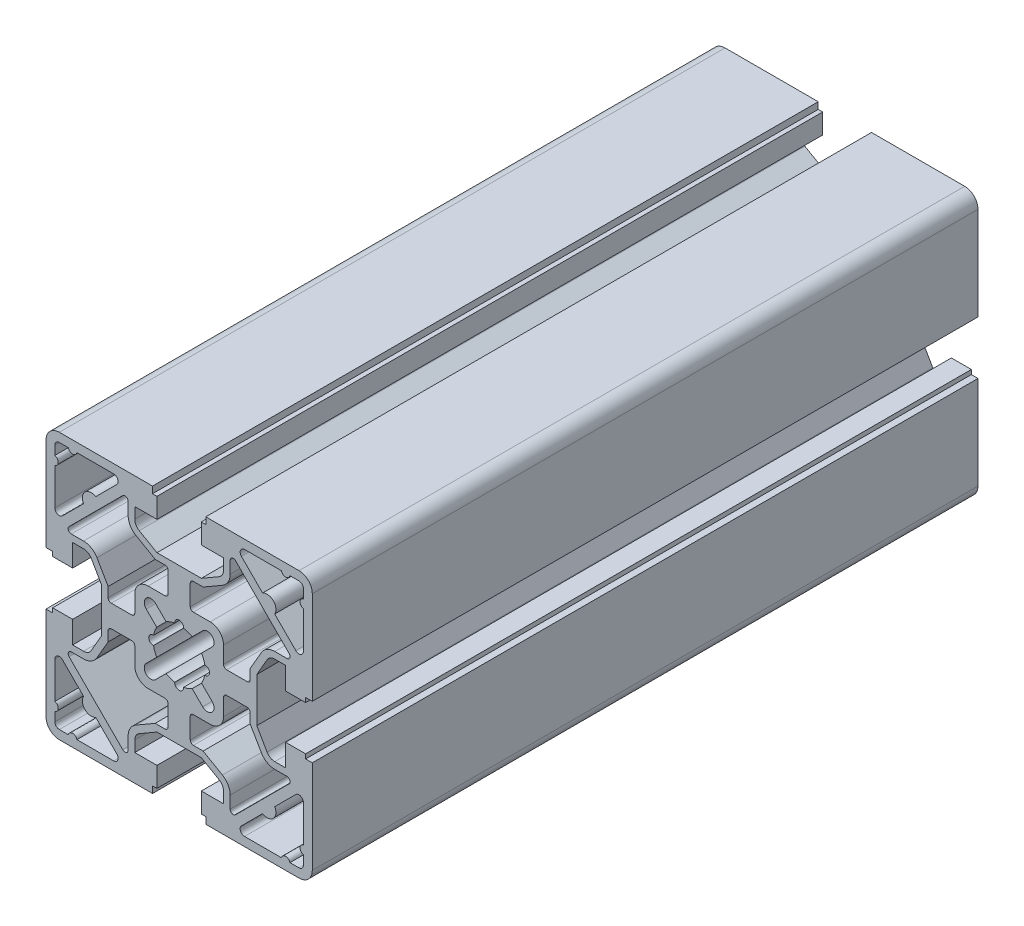
from build123d import *

# Parameters (mm, degrees)
SALIENTE_EXTRUIR1_DEPTH      = 75
TALADRO_DE_MARGEN_PARA_M82_D = 8.4


with BuildPart() as part:
    # Croquis1 → Saliente-Extruir1 (new body, symmetric)
    with BuildSketch(Plane.XY):
        with BuildLine():
            Line((5, 17.5), (-5, 17.5))
            Line((-5, 17.5), (-9, 19.809401077))
            ThreePointArc((-9, 19.809401077), (-9.732050808, 20.541451884), (-10, 21.541451884))
            Line((-10, 21.541451884), (-10, 24))
            Line((-10, 24), (-5, 24))
            Line((-5, 24), (-5, 28.5))
            Line((-5, 28.5), (-6, 28.5))
            Line((-6, 28.5), (-6, 30))
            Line((-6, 30), (-27, 30))
            ThreePointArc((-27, 30), (-29.121320344, 29.121320344), (-30, 27))
            Line((-30, 27), (-30, 6))
            Line((-30, 6), (-28.5, 6))
            Line((-28.5, 6), (-28.5, 5))
            Line((-28.5, 5), (-24, 5))
            Line((-24, 5), (-24, 10))
            Line((-24, 10), (-21.541451884, 10))
            ThreePointArc((-21.541451884, 10), (-20.541451884, 9.732050808), (-19.809401077, 9))
            Line((-19.809401077, 9), (-17.5, 5))
            Line((-17.5, 5), (-17.5, -5))
            Line((-17.5, -5), (-19.809401077, -9))
            ThreePointArc((-19.809401077, -9), (-20.541451884, -9.732050808), (-21.541451884, -10))
            Line((-21.541451884, -10), (-24, -10))
            Line((-24, -10), (-24, -5))
            Line((-24, -5), (-28.5, -5))
            Line((-28.5, -5), (-28.5, -6))
            Line((-28.5, -6), (-30, -6))
            Line((-30, -6), (-30, -27))
            ThreePointArc((-30, -27), (-29.121320344, -29.121320344), (-27, -30))
            Line((-27, -30), (-6, -30))
            Line((-6, -30), (-6, -28.5))
            Line((-6, -28.5), (-5, -28.5))
            Line((-5, -28.5), (-5, -24))
            Line((-5, -24), (-10, -24))
            Line((-10, -24), (-10, -21.541451884))
            ThreePointArc((-10, -21.541451884), (-9.732050808, -20.541451884), (-9, -19.809401077))
            Line((-9, -19.809401077), (-5, -17.5))
            Line((-5, -17.5), (5, -17.5))
            Line((5, -17.5), (9, -19.809401077))
            ThreePointArc((9, -19.809401077), (9.732050808, -20.541451884), (10, -21.541451884))
            Line((10, -21.541451884), (10, -24))
            Line((10, -24), (5, -24))
            Line((5, -24), (5, -28.5))
            Line((5, -28.5), (6, -28.5))
            Line((6, -28.5), (6, -30))
            Line((6, -30), (27, -30))
            ThreePointArc((27, -30), (29.121320344, -29.121320344), (30, -27))
            Line((30, -27), (30, -6))
            Line((30, -6), (28.5, -6))
            Line((28.5, -6), (28.5, -5))
            Line((28.5, -5), (24, -5))
            Line((24, -5), (24, -10))
            Line((24, -10), (21.541451884, -10))
            ThreePointArc((21.541451884, -10), (20.541451884, -9.732050808), (19.809401077, -9))
            Line((19.809401077, -9), (17.5, -5))
            Line((17.5, -5), (17.5, 5))
            Line((17.5, 5), (19.809401077, 9))
            ThreePointArc((19.809401077, 9), (20.541451884, 9.732050808), (21.541451884, 10))
            Line((21.541451884, 10), (24, 10))
            Line((24, 10), (24, 5))
            Line((24, 5), (28.5, 5))
            Line((28.5, 5), (28.5, 6))
            Line((28.5, 6), (30, 6))
            Line((30, 6), (30, 27))
            ThreePointArc((30, 27), (29.121320344, 29.121320344), (27, 30))
            Line((27, 30), (6, 30))
            Line((6, 30), (6, 28.5))
            Line((6, 28.5), (5, 28.5))
            Line((5, 28.5), (5, 24))
            Line((5, 24), (10, 24))
            Line((10, 24), (10, 21.541451884))
            ThreePointArc((10, 21.541451884), (9.732050808, 20.541451884), (9, 19.809401077))
            Line((9, 19.809401077), (5, 17.5))
        make_face()
        with BuildLine():
            ThreePointArc((-21.533519956, -18.794907169), (-21.224873734, -21.224873734), (-18.794907169, -21.533519956))
            Line((-18.794907169, -21.533519956), (-14.035533906, -26.292893219))
            ThreePointArc((-14.035533906, -26.292893219), (-13.818761155, -27.382683432), (-14.742640687, -28))
            Line((-14.742640687, -28), (-23.031754163, -28))
            ThreePointArc((-23.031754163, -28), (-24, -27.25), (-24.968245837, -28))
            Line((-24.968245837, -28), (-27, -28))
            ThreePointArc((-27, -28), (-27.707106781, -27.707106781), (-28, -27))
            Line((-28, -27), (-28, -24.968245837))
            ThreePointArc((-28, -24.968245837), (-27.25, -24), (-28, -23.031754163))
            Line((-28, -23.031754163), (-28, -14.742640687))
            ThreePointArc((-28, -14.742640687), (-27.382683432, -13.818761155), (-26.292893219, -14.035533906))
            Line((-26.292893219, -14.035533906), (-21.533519956, -18.794907169))
        make_face(mode=Mode.SUBTRACT)
        with BuildLine():
            ThreePointArc((-10, -7), (-9.121320344, -9.121320344), (-7, -10))
            Line((-7, -10), (-3.2, -10))
            ThreePointArc((-3.2, -10), (-2.705025253, -10.205025253), (-2.5, -10.7))
            Line((-2.5, -10.7), (-2.5, -15.3))
            ThreePointArc((-2.5, -15.3), (-2.705025253, -15.794974747), (-3.2, -16))
            Line((-3.2, -16), (-5.401923789, -16))
            Line((-5.401923789, -16), (-9.75, -18.510362971))
            ThreePointArc((-9.75, -18.510362971), (-11.031088913, -19.791451884), (-11.5, -21.541451884))
            Line((-11.5, -21.541451884), (-11.5, -24))
            Line((-11.5, -24), (-11.5, -24.310050506))
            ThreePointArc((-11.5, -24.310050506), (-11.932121597, -24.956766179), (-12.694974747, -24.805025253))
            Line((-12.694974747, -24.805025253), (-18.75, -18.75))
            Line((-18.75, -18.75), (-24.805025253, -12.694974747))
            ThreePointArc((-24.805025253, -12.694974747), (-24.956766179, -11.932121597), (-24.310050506, -11.5))
            Line((-24.310050506, -11.5), (-24, -11.5))
            Line((-24, -11.5), (-21.541451884, -11.5))
            ThreePointArc((-21.541451884, -11.5), (-19.791451884, -11.031088913), (-18.510362971, -9.75))
            Line((-18.510362971, -9.75), (-16, -5.401923789))
            Line((-16, -5.401923789), (-16, -3.2))
            ThreePointArc((-16, -3.2), (-15.794974747, -2.705025253), (-15.3, -2.5))
            Line((-15.3, -2.5), (-10.7, -2.5))
            ThreePointArc((-10.7, -2.5), (-10.205025253, -2.705025253), (-10, -3.2))
            Line((-10, -3.2), (-10, -7))
        make_face(mode=Mode.SUBTRACT)
        with BuildLine():
            ThreePointArc((18.794907169, -21.533519956), (21.224873734, -21.224873734), (21.533519956, -18.794907169))
            Line((21.533519956, -18.794907169), (26.292893219, -14.035533906))
            ThreePointArc((26.292893219, -14.035533906), (27.382683432, -13.818761155), (28, -14.742640687))
            Line((28, -14.742640687), (28, -23.031754163))
            ThreePointArc((28, -23.031754163), (27.25, -24), (28, -24.968245837))
            Line((28, -24.968245837), (28, -27))
            ThreePointArc((28, -27), (27.707106781, -27.707106781), (27, -28))
            Line((27, -28), (24.968245837, -28))
            ThreePointArc((24.968245837, -28), (24, -27.25), (23.031754163, -28))
            Line((23.031754163, -28), (14.742640687, -28))
            ThreePointArc((14.742640687, -28), (13.818761155, -27.382683432), (14.035533906, -26.292893219))
            Line((14.035533906, -26.292893219), (18.794907169, -21.533519956))
        make_face(mode=Mode.SUBTRACT)
        with BuildLine():
            ThreePointArc((7, -10), (9.121320344, -9.121320344), (10, -7))
            Line((10, -7), (10, -3.2))
            ThreePointArc((10, -3.2), (10.205025253, -2.705025253), (10.7, -2.5))
            Line((10.7, -2.5), (15.3, -2.5))
            ThreePointArc((15.3, -2.5), (15.794974747, -2.705025253), (16, -3.2))
            Line((16, -3.2), (16, -5.401923789))
            Line((16, -5.401923789), (18.510362971, -9.75))
            ThreePointArc((18.510362971, -9.75), (19.791451884, -11.031088913), (21.541451884, -11.5))
            Line((21.541451884, -11.5), (24, -11.5))
            Line((24, -11.5), (24.310050506, -11.5))
            ThreePointArc((24.310050506, -11.5), (24.956766179, -11.932121597), (24.805025253, -12.694974747))
            Line((24.805025253, -12.694974747), (18.75, -18.75))
            Line((18.75, -18.75), (12.694974747, -24.805025253))
            ThreePointArc((12.694974747, -24.805025253), (11.932121597, -24.956766179), (11.5, -24.310050506))
            Line((11.5, -24.310050506), (11.5, -24))
            Line((11.5, -24), (11.5, -21.541451884))
            ThreePointArc((11.5, -21.541451884), (11.031088913, -19.791451884), (9.75, -18.510362971))
            Line((9.75, -18.510362971), (5.401923789, -16))
            Line((5.401923789, -16), (3.2, -16))
            ThreePointArc((3.2, -16), (2.705025253, -15.794974747), (2.5, -15.3))
            Line((2.5, -15.3), (2.5, -10.7))
            ThreePointArc((2.5, -10.7), (2.705025253, -10.205025253), (3.2, -10))
            Line((3.2, -10), (7, -10))
        make_face(mode=Mode.SUBTRACT)
        with BuildLine():
            ThreePointArc((1, -5.85), (0, -6.85), (-1, -5.85))
            Line((-1, -5.85), (-1, -5.763896252))
            ThreePointArc((-1, -5.763896252), (-2.000113664, -5.497458079), (-2.937620709, -5.058941052))
            Line((-2.937620709, -5.058941052), (-5.303300859, -7.424621202))
            ThreePointArc((-5.303300859, -7.424621202), (-7.424621202, -7.424621202), (-7.424621202, -5.303300859))
            Line((-7.424621202, -5.303300859), (-5.058941052, -2.937620709))
            ThreePointArc((-5.058941052, -2.937620709), (-5.497458079, -2.000113664), (-5.763896252, -1))
            Line((-5.763896252, -1), (-5.85, -1))
            ThreePointArc((-5.85, -1), (-6.85, 0), (-5.85, 1))
            Line((-5.85, 1), (-5.763896252, 1))
            ThreePointArc((-5.763896252, 1), (-5.497458079, 2.000113664), (-5.058941052, 2.937620709))
            Line((-5.058941052, 2.937620709), (-7.424621202, 5.303300859))
            ThreePointArc((-7.424621202, 5.303300859), (-7.424621202, 7.424621202), (-5.303300859, 7.424621202))
            Line((-5.303300859, 7.424621202), (-2.937620709, 5.058941052))
            ThreePointArc((-2.937620709, 5.058941052), (-2.000113664, 5.497458079), (-1, 5.763896252))
            Line((-1, 5.763896252), (-1, 5.85))
            ThreePointArc((-1, 5.85), (0, 6.85), (1, 5.85))
            Line((1, 5.85), (1, 5.763896252))
            ThreePointArc((1, 5.763896252), (2.000113664, 5.497458079), (2.937620709, 5.058941052))
            Line((2.937620709, 5.058941052), (5.303300859, 7.424621202))
            ThreePointArc((5.303300859, 7.424621202), (7.424621202, 7.424621202), (7.424621202, 5.303300859))
            Line((7.424621202, 5.303300859), (5.058941052, 2.937620709))
            ThreePointArc((5.058941052, 2.937620709), (5.497458079, 2.000113664), (5.763896252, 1))
            Line((5.763896252, 1), (5.85, 1))
            ThreePointArc((5.85, 1), (6.85, 0), (5.85, -1))
            Line((5.85, -1), (5.763896252, -1))
            ThreePointArc((5.763896252, -1), (5.497458079, -2.000113664), (5.058941052, -2.937620709))
            Line((5.058941052, -2.937620709), (7.424621202, -5.303300859))
            ThreePointArc((7.424621202, -5.303300859), (7.424621202, -7.424621202), (5.303300859, -7.424621202))
            Line((5.303300859, -7.424621202), (2.937620709, -5.058941052))
            ThreePointArc((2.937620709, -5.058941052), (2.000113664, -5.497458079), (1, -5.763896252))
            Line((1, -5.763896252), (1, -5.85))
        make_face(mode=Mode.SUBTRACT)
        with BuildLine():
            Line((-3.2, 10), (-7, 10))
            ThreePointArc((-7, 10), (-9.121320344, 9.121320344), (-10, 7))
            Line((-10, 7), (-10, 3.2))
            ThreePointArc((-10, 3.2), (-10.205025253, 2.705025253), (-10.7, 2.5))
            Line((-10.7, 2.5), (-15.3, 2.5))
            ThreePointArc((-15.3, 2.5), (-15.794974747, 2.705025253), (-16, 3.2))
            Line((-16, 3.2), (-16, 5.401923789))
            Line((-16, 5.401923789), (-18.510362971, 9.75))
            ThreePointArc((-18.510362971, 9.75), (-19.791451884, 11.031088913), (-21.541451884, 11.5))
            Line((-21.541451884, 11.5), (-24, 11.5))
            Line((-24, 11.5), (-24.310050506, 11.5))
            ThreePointArc((-24.310050506, 11.5), (-24.956766179, 11.932121597), (-24.805025253, 12.694974747))
            Line((-24.805025253, 12.694974747), (-18.75, 18.75))
            Line((-18.75, 18.75), (-12.694974747, 24.805025253))
            ThreePointArc((-12.694974747, 24.805025253), (-11.932121597, 24.956766179), (-11.5, 24.310050506))
            Line((-11.5, 24.310050506), (-11.5, 24))
            Line((-11.5, 24), (-11.5, 21.541451884))
            ThreePointArc((-11.5, 21.541451884), (-11.031088913, 19.791451884), (-9.75, 18.510362971))
            Line((-9.75, 18.510362971), (-5.401923789, 16))
            Line((-5.401923789, 16), (-3.2, 16))
            ThreePointArc((-3.2, 16), (-2.705025253, 15.794974747), (-2.5, 15.3))
            Line((-2.5, 15.3), (-2.5, 10.7))
            ThreePointArc((-2.5, 10.7), (-2.705025253, 10.205025253), (-3.2, 10))
        make_face(mode=Mode.SUBTRACT)
        with BuildLine():
            Line((-14.035533906, 26.292893219), (-18.794907169, 21.533519956))
            ThreePointArc((-18.794907169, 21.533519956), (-21.224873734, 21.224873734), (-21.533519956, 18.794907169))
            Line((-21.533519956, 18.794907169), (-26.292893219, 14.035533906))
            ThreePointArc((-26.292893219, 14.035533906), (-27.382683432, 13.818761155), (-28, 14.742640687))
            Line((-28, 14.742640687), (-28, 23.031754163))
            ThreePointArc((-28, 23.031754163), (-27.25, 24), (-28, 24.968245837))
            Line((-28, 24.968245837), (-28, 27))
            ThreePointArc((-28, 27), (-27.707106781, 27.707106781), (-27, 28))
            Line((-27, 28), (-24.968245837, 28))
            ThreePointArc((-24.968245837, 28), (-24, 27.25), (-23.031754163, 28))
            Line((-23.031754163, 28), (-14.742640687, 28))
            ThreePointArc((-14.742640687, 28), (-13.818761155, 27.382683432), (-14.035533906, 26.292893219))
        make_face(mode=Mode.SUBTRACT)
        with BuildLine():
            Line((15.3, 2.5), (10.7, 2.5))
            ThreePointArc((10.7, 2.5), (10.205025253, 2.705025253), (10, 3.2))
            Line((10, 3.2), (10, 7))
            ThreePointArc((10, 7), (9.121320344, 9.121320344), (7, 10))
            Line((7, 10), (3.2, 10))
            ThreePointArc((3.2, 10), (2.705025253, 10.205025253), (2.5, 10.7))
            Line((2.5, 10.7), (2.5, 15.3))
            ThreePointArc((2.5, 15.3), (2.705025253, 15.794974747), (3.2, 16))
            Line((3.2, 16), (5.401923789, 16))
            Line((5.401923789, 16), (9.75, 18.510362971))
            ThreePointArc((9.75, 18.510362971), (11.031088913, 19.791451884), (11.5, 21.541451884))
            Line((11.5, 21.541451884), (11.5, 24))
            Line((11.5, 24), (11.5, 24.310050506))
            ThreePointArc((11.5, 24.310050506), (11.932121597, 24.956766179), (12.694974747, 24.805025253))
            Line((12.694974747, 24.805025253), (18.75, 18.75))
            Line((18.75, 18.75), (24.805025253, 12.694974747))
            ThreePointArc((24.805025253, 12.694974747), (24.956766179, 11.932121597), (24.310050506, 11.5))
            Line((24.310050506, 11.5), (24, 11.5))
            Line((24, 11.5), (21.541451884, 11.5))
            ThreePointArc((21.541451884, 11.5), (19.791451884, 11.031088913), (18.510362971, 9.75))
            Line((18.510362971, 9.75), (16, 5.401923789))
            Line((16, 5.401923789), (16, 3.2))
            ThreePointArc((16, 3.2), (15.794974747, 2.705025253), (15.3, 2.5))
        make_face(mode=Mode.SUBTRACT)
        with BuildLine():
            ThreePointArc((21.533519956, 18.794907169), (21.224873734, 21.224873734), (18.794907169, 21.533519956))
            Line((18.794907169, 21.533519956), (14.035533906, 26.292893219))
            ThreePointArc((14.035533906, 26.292893219), (13.818761155, 27.382683432), (14.742640687, 28))
            Line((14.742640687, 28), (23.031754163, 28))
            ThreePointArc((23.031754163, 28), (24, 27.25), (24.968245837, 28))
            Line((24.968245837, 28), (27, 28))
            ThreePointArc((27, 28), (27.707106781, 27.707106781), (28, 27))
            Line((28, 27), (28, 24.968245837))
            ThreePointArc((28, 24.968245837), (27.25, 24), (28, 23.031754163))
            Line((28, 23.031754163), (28, 14.742640687))
            ThreePointArc((28, 14.742640687), (27.382683432, 13.818761155), (26.292893219, 14.035533906))
            Line((26.292893219, 14.035533906), (21.533519956, 18.794907169))
        make_face(mode=Mode.SUBTRACT)
    extrude(amount=SALIENTE_EXTRUIR1_DEPTH, both=True)

    # Taladro de margen para M82 (through all)
    with Locations(Plane(origin=(0, 30, 0), x_dir=(1, 0, 0), z_dir=(0, 1, 0))):
        with Locations((0, 40), (0, -40)):
            Hole(TALADRO_DE_MARGEN_PARA_M82_D / 2)


solid = part.part
